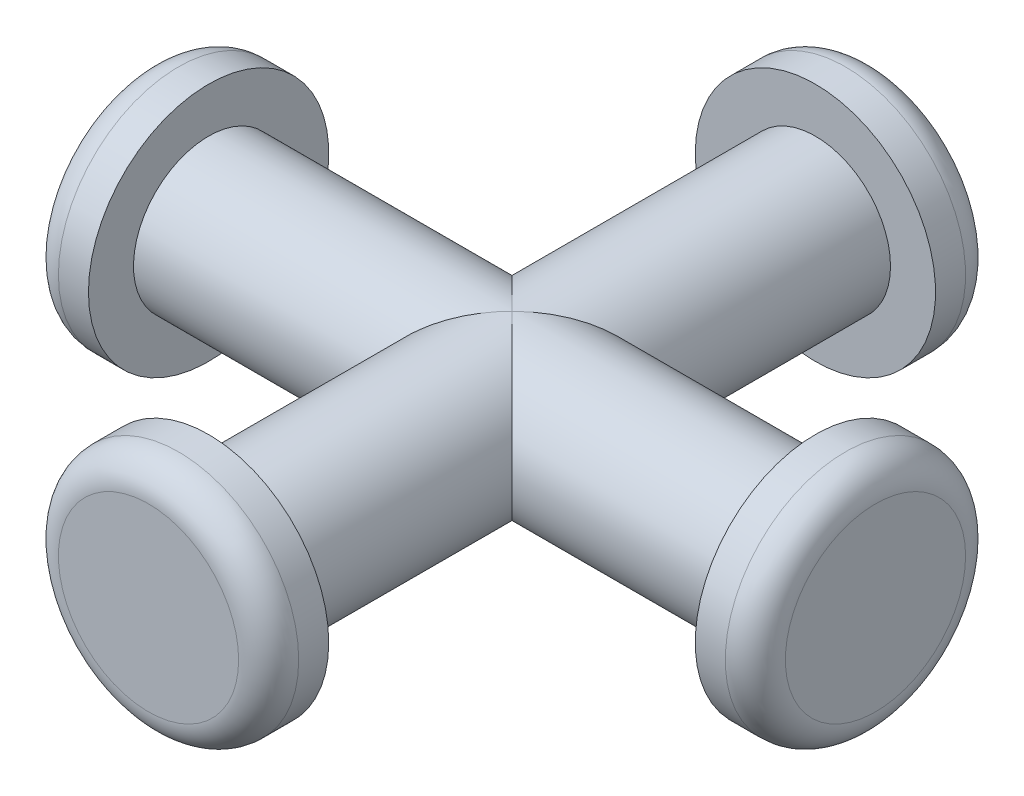
from build123d import *

# Parameters (mm, degrees)
ESQUISSE1_R        = 2.5
BOSS_EXTRU_1_DEPTH = 10.1
ESQUISSE3_R        = 2.5
BOSS_EXTRU_2_DEPTH = 10.1
ESQUISSE4_R        = 4
BOSS_EXTRU_3_DEPTH = 2
ESQUISSE5_R        = 4
BOSS_EXTRU_4_DEPTH = 2
ESQUISSE6_R        = 4
BOSS_EXTRU_5_DEPTH = 2
ESQUISSE7_R        = 4
BOSS_EXTRU_6_DEPTH = 2
CONG_1_R           = 1


with BuildPart() as part:
    # Esquisse1 → Boss.-Extru.1 (new body, symmetric)
    with BuildSketch(Plane.XY):
        Circle(ESQUISSE1_R)
    extrude(amount=BOSS_EXTRU_1_DEPTH, both=True)

    # Esquisse3 → Boss.-Extru.2 (add, symmetric)
    with BuildSketch(Plane(origin=(0, 0, 0), x_dir=(0, 0, -1), z_dir=(1, 0, 0))):
        with Locations(Location((0, 0, 0), (0, 0, 270))):  # turned: the seam where the file's is
            Circle(ESQUISSE3_R)
    extrude(amount=BOSS_EXTRU_2_DEPTH, both=True)

    # Esquisse4 → Boss.-Extru.3 (add)
    with BuildSketch(Plane(origin=(10.1, 0, 0), x_dir=(0, 0, -1), z_dir=(1, 0, 0))):
        Circle(ESQUISSE4_R)
    extrude(amount=BOSS_EXTRU_3_DEPTH)

    # Esquisse5 → Boss.-Extru.4 (add)
    with BuildSketch(Plane.ZY.offset(10.1)):
        with Locations(Location((0, 0, 0), (0, 0, 180))):  # turned: the seam where the file's is
            Circle(ESQUISSE5_R)
    extrude(amount=BOSS_EXTRU_4_DEPTH)

    # Esquisse6 → Boss.-Extru.5 (add)
    with BuildSketch(Plane.XY.offset(10.1)):
        Circle(ESQUISSE6_R)
    extrude(amount=BOSS_EXTRU_5_DEPTH)

    # Esquisse7 → Boss.-Extru.6 (add)
    with BuildSketch(Plane(origin=(0, 0, -10.1), x_dir=(-1, 0, 0), z_dir=(0, 0, -1))):
        with Locations(Location((0, 0, 0), (0, 0, 180))):  # turned: the seam where the file's is
            Circle(ESQUISSE7_R)
    extrude(amount=BOSS_EXTRU_6_DEPTH)

    # Congé1
    cong_1_edges = [part.edges().sort_by_distance(p)[0] for p in [
        (12.1, 0, 4),
        (-12.1, 0, 4),
        (-4, 0, 12.1),
        (-4, 0, -12.1),
    ]]
    fillet(cong_1_edges, radius=CONG_1_R)


solid = part.part
